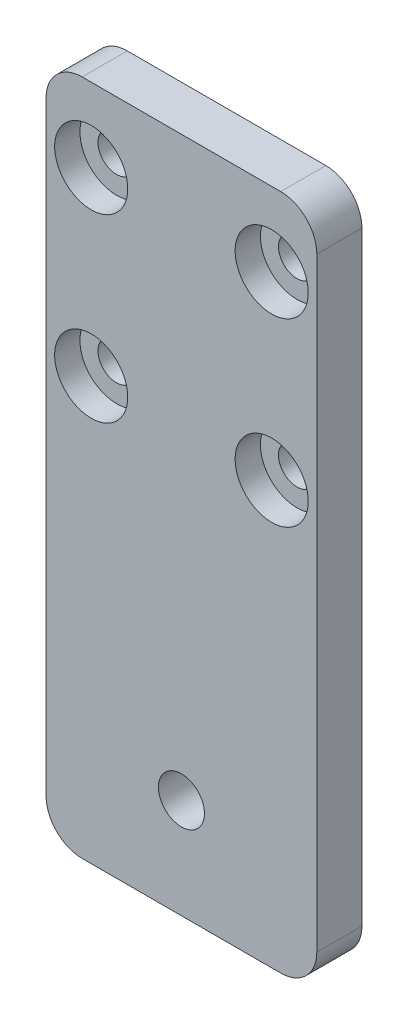
from build123d import *

# Parameters (mm, degrees)
CROQUIS1_W              = 30
CROQUIS1_H              = 75
CROQUIS1_R              = 2.05
CROQUIS1_R_2            = 2.55
SALIENTE_EXTRUIR1_DEPTH = 5
REDONDEO1_R             = 4
CROQUIS4_R              = 4.05
CORTAR_EXTRUIR1_DEPTH   = 2.8


with BuildPart() as part:
    # Croquis1 → Saliente-Extruir1 (new body)
    with BuildSketch(Plane.XY):
        with Locations((15, 37.5)):
            Rectangle(CROQUIS1_W, CROQUIS1_H)
        with Locations((5, 66.8)):
            Circle(CROQUIS1_R, mode=Mode.SUBTRACT)
        with Locations((25, 66.8)):
            Circle(CROQUIS1_R, mode=Mode.SUBTRACT)
        with Locations((25, 46.8)):
            Circle(CROQUIS1_R, mode=Mode.SUBTRACT)
        with Locations((5, 46.8)):
            Circle(CROQUIS1_R, mode=Mode.SUBTRACT)
        with Locations((15, 11.08)):
            Circle(CROQUIS1_R_2, mode=Mode.SUBTRACT)
    extrude(amount=SALIENTE_EXTRUIR1_DEPTH)

    # Redondeo1
    redondeo1_edges = [part.edges().sort_by_distance(p)[0] for p in [
        (0, 75, 2.5),
        (30, 75, 2.5),
        (30, 0, 2.5),
        (0, 0, 2.5),
    ]]
    fillet(redondeo1_edges, radius=REDONDEO1_R)

    # Croquis4 → Cortar-Extruir1 (cut)
    with BuildSketch(Plane.XY.offset(5)):
        with Locations((5, 66.8)):
            Circle(CROQUIS4_R)
        with Locations((5, 46.8)):
            Circle(CROQUIS4_R)
        with Locations((25, 46.8)):
            Circle(CROQUIS4_R)
        with Locations((25, 66.8)):
            Circle(CROQUIS4_R)
    extrude(amount=-CORTAR_EXTRUIR1_DEPTH, mode=Mode.SUBTRACT)


solid = part.part
